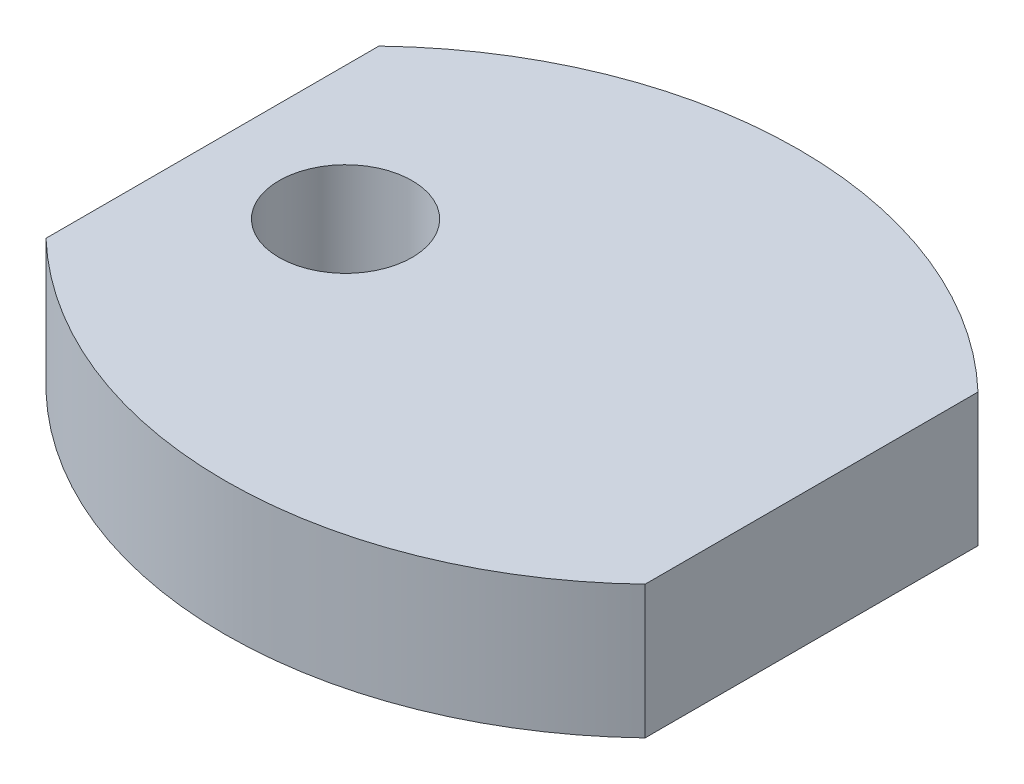
from build123d import *

# Parameters (mm, degrees)
SKETCH1_R           = 2
BOSS_EXTRUDE1_DEPTH = 4


with BuildPart() as part:
    # Sketch1 → Boss-Extrude1 (new body)
    with BuildSketch(Plane(origin=(0, 0, 0), x_dir=(1, 0, 0), z_dir=(0, 1, 0))):
        with BuildLine():
            Line((9, -5), (9, 5))
            ThreePointArc((9, 5), (0, 8.61916848), (-9, 5))
            Line((-9, 5), (-9, -5))
            ThreePointArc((-9, -5), (0, -8.61916848), (9, -5))
        make_face()
        with Locations((-5, 0)):
            Circle(SKETCH1_R, mode=Mode.SUBTRACT)
    extrude(amount=BOSS_EXTRUDE1_DEPTH)


solid = part.part
